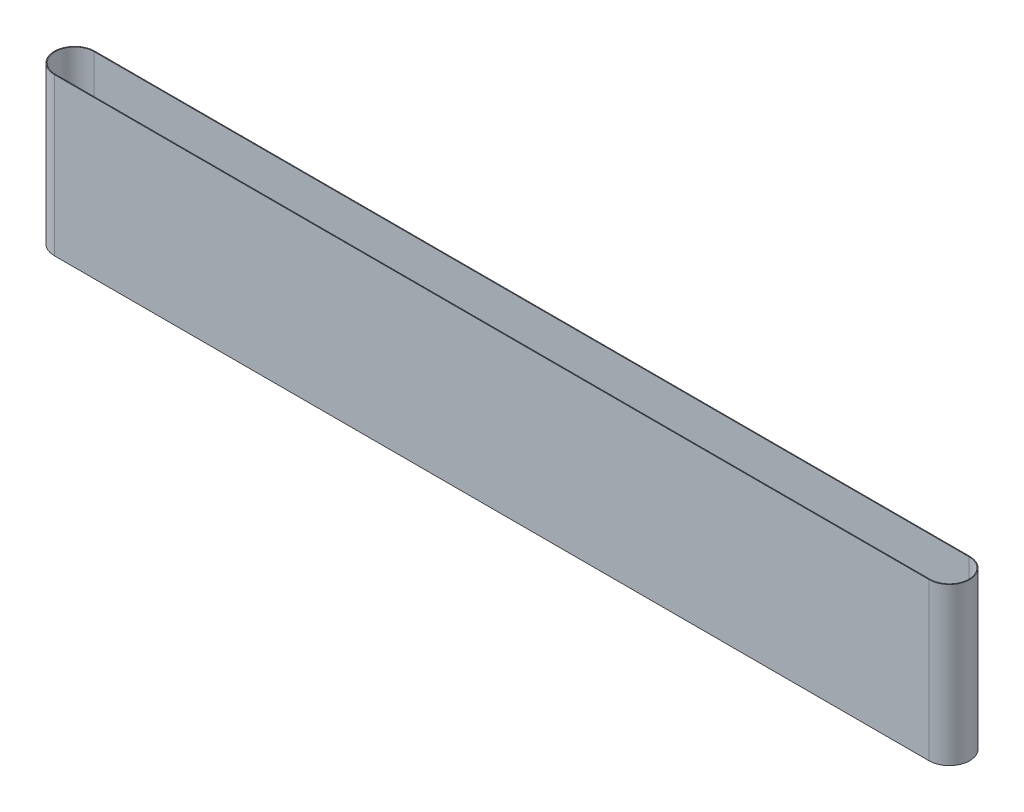
from build123d import *

# Parameters (mm, degrees)
EXTRUDE_THIN1_DEPTH = 205


with BuildPart() as part:
    # Sketch1 → Extrude-Thin1 (new body)
    with BuildSketch(Plane(origin=(0, 0, 0), x_dir=(1, 0, 0), z_dir=(0, 1, 0))):
        with BuildLine():
            Line((1071.675111413, -13.104812649), (-71.124888587, -13.104812649))
            ThreePointArc((-71.124888587, -13.104812649), (-97.624888587, 13.395187351), (-71.124888587, 39.895187351))
            Line((-71.124888587, 39.895187351), (1071.675111413, 39.895187351))
            ThreePointArc((1071.675111413, 39.895187351), (1098.175111413, 13.395187351), (1071.675111413, -13.104812649))
        make_face()
        with BuildLine():
            Line((1071.675111413, -12.104812649), (-71.124888587, -12.104812649))
            ThreePointArc((-71.124888587, -12.104812649), (-96.624888587, 13.395187351), (-71.124888587, 38.895187351))
            Line((-71.124888587, 38.895187351), (1071.675111413, 38.895187351))
            ThreePointArc((1071.675111413, 38.895187351), (1097.175111413, 13.395187351), (1071.675111413, -12.104812649))
        make_face(mode=Mode.SUBTRACT)
    extrude(amount=EXTRUDE_THIN1_DEPTH)


solid = part.part
